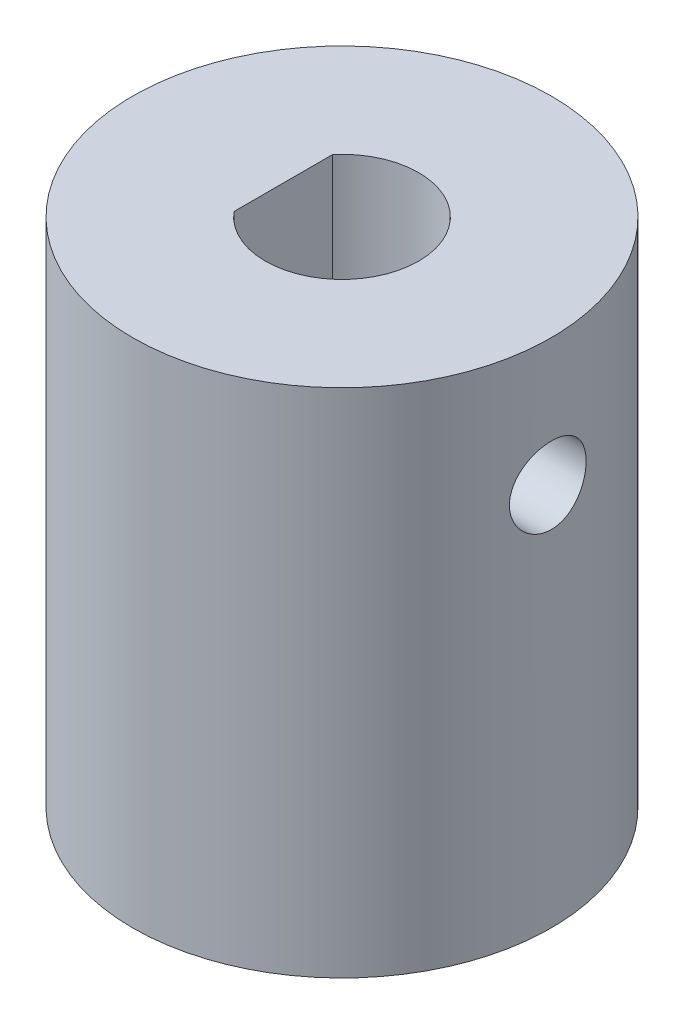
from build123d import *

# Parameters (mm, degrees)
SKETCH1_R               = 8.189006913
BOSS_EXTRUDE1_DEPTH     = 20
SKETCH2_R               = 3
CUT_EXTRUDE1_DEPTH      = 30
SKETCH4_W               = 1.839212521
SKETCH4_H               = 4.190652527
BOSS_EXTRUDE2_DEPTH     = 10
CUT_EXTRUDE2_DEPTH      = 10
CUT_EXTRUDE2_DEPTH_BACK = 10
SKETCH3_R               = 1.5


with BuildPart() as part:
    # Sketch1 → Boss-Extrude1 (new body)
    with BuildSketch(Plane(origin=(0, 0, 0), x_dir=(1, 0, 0), z_dir=(0, 1, 0))):
        Circle(SKETCH1_R)
    extrude(amount=BOSS_EXTRUDE1_DEPTH)

    # Sketch2 → Cut-Extrude1 (cut)
    with BuildSketch(Plane(origin=(0, 20, 0), x_dir=(1, 0, 0), z_dir=(0, 1, 0))):
        Circle(SKETCH2_R)
    extrude(amount=-CUT_EXTRUDE1_DEPTH, mode=Mode.SUBTRACT)

    # Sketch4 → Boss-Extrude2 (add)
    with BuildSketch(Plane(origin=(0, 20, 0), x_dir=(1, 0, 0), z_dir=(0, 1, 0))):
        with Locations((-3.214713917, 0.163363311)):
            Rectangle(SKETCH4_W, SKETCH4_H)
    extrude(amount=-BOSS_EXTRUDE2_DEPTH)

    # Sketch3 → Cut-Extrude2 (cut, two sides: drawn at the far end of the back side and taken through both)
    with BuildSketch(Plane(origin=(0, 0, 0), x_dir=(0, 0, -1), z_dir=(1, 0, 0)).offset(-CUT_EXTRUDE2_DEPTH_BACK)):
        with Locations((0, 15)):
            Circle(SKETCH3_R)
    extrude(amount=CUT_EXTRUDE2_DEPTH + CUT_EXTRUDE2_DEPTH_BACK, mode=Mode.SUBTRACT)


solid = part.part
